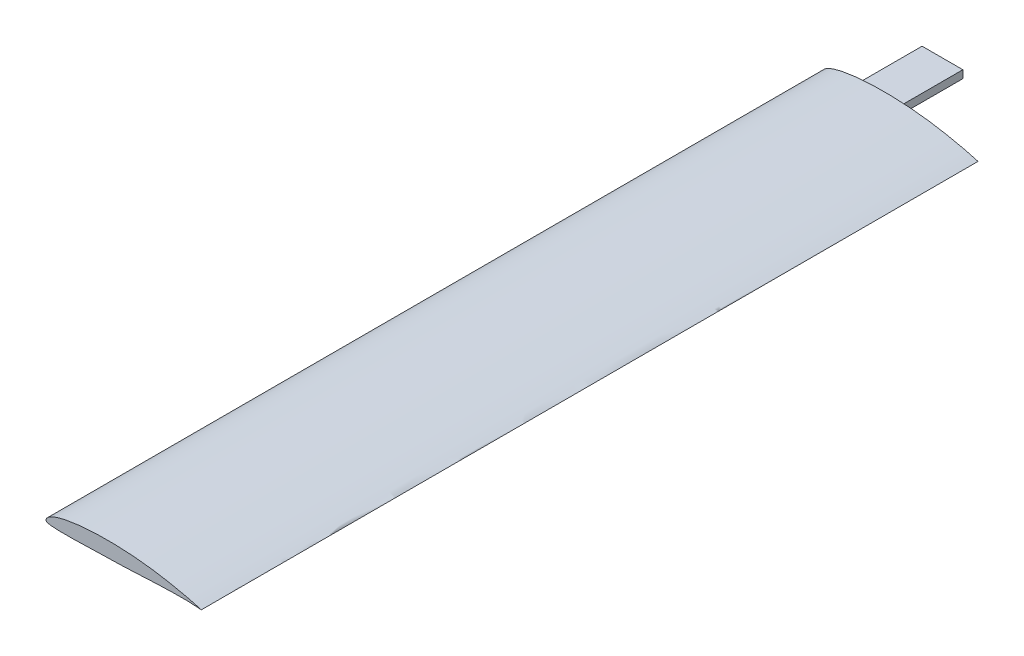
from build123d import *

# Parameters (mm, degrees)
BOSS_EXTRUDE1_DEPTH = 100
SKETCH3_W           = 5.25
SKETCH3_H           = 1
BOSS_EXTRUDE2_DEPTH = 8


with BuildPart() as part:
    # Sketch1 → Boss-Extrude1 (new body)
    with BuildSketch(Plane.XY):
        with BuildLine():
            add(Edge.make_bspline(
                [(20, 0), (20.0000617, 0.000713723), (19.918687647, 0.018860516), (19.839058016, 0.044758755), (19.650777316, 0.099272077), (19.426692916, 0.167829756), (19.140319282, 0.251016201), (18.804647653, 0.340685843), (18.416373864, 0.435228853), (17.97942794, 0.536783049), (17.496431422, 0.644261738), (16.971885827, 0.756317908), (16.410206727, 0.871962751), (15.815702292, 0.988126599), (15.193333491, 1.103626236), (14.546514292, 1.214252212), (13.877620091, 1.31540292), (13.189577003, 1.408149222), (12.485229401, 1.490728304), (11.768283488, 1.561834174), (11.042393028, 1.622097194), (10.311276748, 1.670380388), (9.578796447, 1.705810812), (8.848867181, 1.729403152), (8.125301515, 1.739200465), (7.412002244, 1.737177905), (6.712810128, 1.722183565), (6.031686362, 1.694501017), (5.372315817, 1.655302168), (4.738367505, 1.604361912), (4.13337415, 1.541589301), (3.560518803, 1.46865979), (3.023049626, 1.384950708), (2.523566236, 1.292566663), (2.06480058, 1.190959036), (1.649079547, 1.081414285), (1.277993022, 0.965584304), (0.953509244, 0.84229737), (0.676287066, 0.714471377), (0.446514586, 0.583119286), (0.26505444, 0.447953695), (0.129663159, 0.315035252), (0.038650806, 0.183213804), (0.001336743, 0.059821582), (-0.0052827, -0.059602262), (0.08657487, -0.151538208), (0.23239101, -0.202757565), (0.432924492, -0.257999047), (0.695579927, -0.295499248), (1.018217067, -0.322892672), (1.401706517, -0.339960306), (1.84366453, -0.350523766), (2.341264114, -0.354330122), (2.890621261, -0.353552604), (3.487832077, -0.347752511), (4.128702986, -0.338510921), (4.808702734, -0.325865061), (5.523031672, -0.310268316), (6.26669539, -0.292190964), (7.034552815, -0.27163259), (7.821356678, -0.249312497), (8.621635616, -0.224647035), (9.430256146, -0.196832977), (10.242727257, -0.164779132), (11.055314931, -0.128821575), (11.864355356, -0.090036567), (12.665636528, -0.049846597), (13.454261838, -0.010949683), (14.224767938, 0.024585503), (14.971103629, 0.054723), (15.686970388, 0.07897397), (16.366205277, 0.095571446), (17.002628225, 0.104939148), (17.59050778, 0.107101991), (18.123979669, 0.101811209), (18.598436762, 0.091088822), (19.007407369, 0.075537762), (19.352020305, 0.05685892), (19.61462514, 0.039762473), (19.827179524, 0.01859811), (19.914882705, 0.012388345), (19.999937734, -0.000720269), (20, 0)],
                knots=[0, 0, 0, 0, 0.000980753, 0.003818066, 0.008307051, 0.014259745, 0.021543994, 0.030087361, 0.039894966, 0.050943083, 0.06311863, 0.076320382, 0.090431682, 0.105336052, 0.120914795, 0.137031897, 0.153643772, 0.170715876, 0.188141572, 0.205850125, 0.223753841, 0.241763154, 0.259789289, 0.277739644, 0.2955258, 0.313060251, 0.330250401, 0.347008909, 0.363243004, 0.378875911, 0.393826638, 0.408017845, 0.421385186, 0.433866928, 0.445407465, 0.455969556, 0.465508428, 0.474013429, 0.481506411, 0.487961274, 0.493465501, 0.498108565, 0.501907593, 0.505060686, 0.507629983, 0.510152512, 0.513900059, 0.518981961, 0.525445327, 0.53339209, 0.542820301, 0.553698437, 0.56593805, 0.579453187, 0.594141873, 0.60990636, 0.626638895, 0.64421195, 0.662507707, 0.681403506, 0.700761807, 0.720455451, 0.74034791, 0.760327433, 0.780315809, 0.800228945, 0.819957275, 0.839380253, 0.858358071, 0.876741993, 0.894369907, 0.911089883, 0.926761139, 0.9412284, 0.954366215, 0.966044044, 0.976141018, 0.984569134, 0.991239946, 0.996068597, 0.999010251, 1, 1, 1, 1], degree=3))
        make_face()
    extrude(amount=BOSS_EXTRUDE1_DEPTH)

    # Sketch3 → Boss-Extrude2 (add)
    with BuildSketch(Plane(origin=(0, 0, 0), x_dir=(-1, 0, 0), z_dir=(0, 0, -1))):
        with Locations((-7.425, 0.75)):
            Rectangle(SKETCH3_W, SKETCH3_H)
    extrude(amount=BOSS_EXTRUDE2_DEPTH)


solid = part.part
